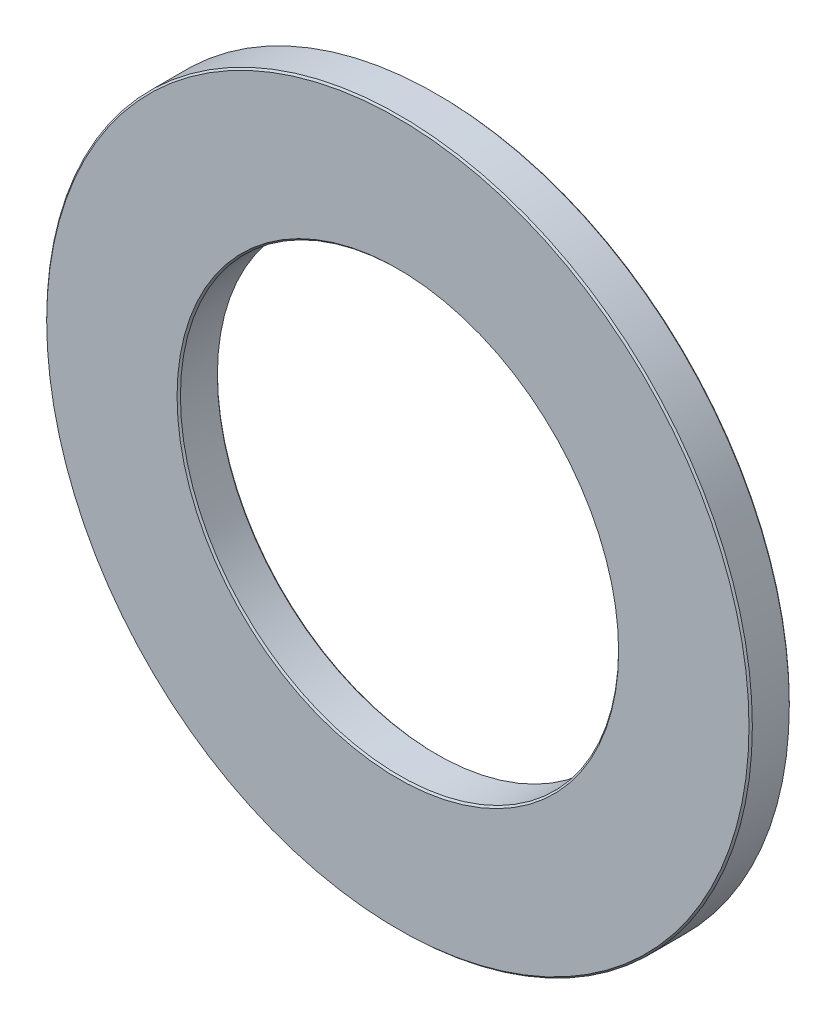
from build123d import *

# Parameters (mm, degrees)
SKETCH1_R           = 52.5
SKETCH1_R_2         = 32.6
BOSS_EXTRUDE1_DEPTH = 6
CHAMFER1_SIZE       = 0.25


with BuildPart() as part:
    # Sketch1 → Boss-Extrude1 (new body)
    with BuildSketch(Plane.XY):
        Circle(SKETCH1_R)
        Circle(SKETCH1_R_2, mode=Mode.SUBTRACT)
    extrude(amount=BOSS_EXTRUDE1_DEPTH)

    # Chamfer1
    chamfer1_edges = [part.edges().sort_by_distance(p)[0] for p in [
        (-52.5, 0, 0),
        (-52.5, 0, 6),
        (-32.6, 0, 0),
        (-32.6, 0, 6),
    ]]
    chamfer(chamfer1_edges, length=CHAMFER1_SIZE)


solid = part.part
